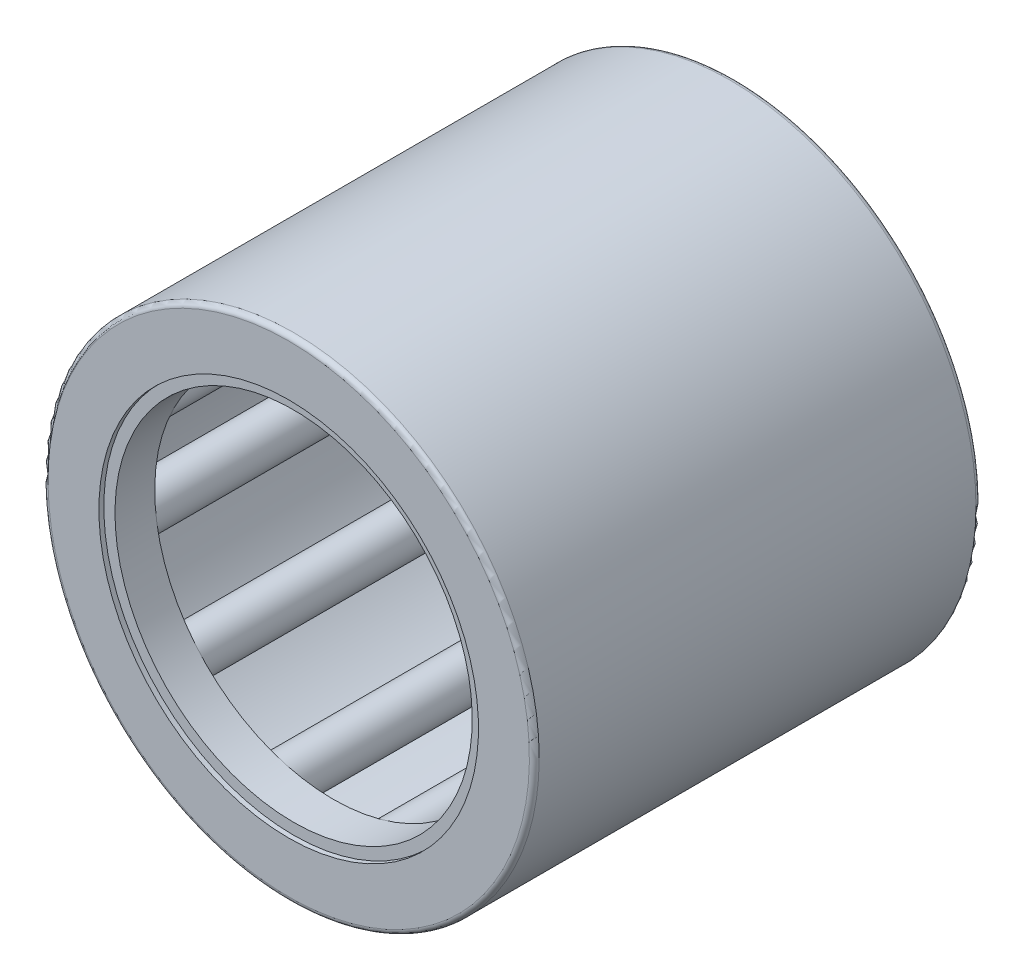
from build123d import *

# Parameters (mm, degrees)
SKETCH2_W         = 12.7
SKETCH2_H         = 0.5953125
SKETCH3_W         = 14.2875
SKETCH3_H         = 0.1984375
CIRPATTERN1_COUNT = 11
CIRPATTERN1_ANGLE = 327.272727273
FILLET1_R         = 0.174625
SKETCH4_W         = 1.412875
SKETCH4_H         = 0.396875
SKETCH5_W         = 1.412875
SKETCH5_H         = 0.396875


with BuildPart() as part:
    # Sketch1 → Revolve1 (revolve)
    with BuildSketch(Plane(origin=(0, 0, 0), x_dir=(0, 0, -1), z_dir=(1, 0, 0))):
        Polygon((-7.9375, 8.73125), (7.9375, 8.73125), (7.9375, 6.746875), (7.14375, 6.746875), (7.14375, 7.9375), (-7.14375, 7.9375), (-7.14375, 6.746875), (-7.9375, 6.746875), align=None)
    revolve(axis=Axis((0, 0, 7.9375), (0, 0, -1)))

    # Fillet1
    fillet1_edges = [part.edges().sort_by_distance(p)[0] for p in [
        (0, -8.73125, -7.9375),
        (0, -8.73125, 7.9375),
    ]]
    fillet(fillet1_edges, radius=FILLET1_R)


with BuildPart() as body_2:
    # Sketch2 → Revolve2 (revolve)
    with BuildSketch(Plane(origin=(0, 0, 0), x_dir=(0, 0, -1), z_dir=(1, 0, 0))):
        with Locations((0, 7.63984375)):
            Rectangle(SKETCH2_W, SKETCH2_H)
    revolve(axis=Axis((0, 7.14375, 6.35), (0, 0, -1)))


with BuildPart() as body_3:
    # Sketch3 → Revolve3 (revolve)
    with BuildSketch(Plane(origin=(0, 0, 0), x_dir=(0, 0, -1), z_dir=(1, 0, 0))):
        with Locations((0, 7.24296875)):
            Rectangle(SKETCH3_W, SKETCH3_H)
    revolve(axis=Axis((0, 7.14375, 7.14375), (0, 0, -1)))


with BuildPart() as cirpattern1_1:
    # CirPattern1: pattern copy
    add(body_2.part.rotate(Axis((0, 0, -7.9375), (0, 0, 1)), 1 * CIRPATTERN1_ANGLE / (CIRPATTERN1_COUNT - 1)))


with BuildPart() as cirpattern1_2:
    # CirPattern1: pattern copy
    add(body_2.part.rotate(Axis((0, 0, -7.9375), (0, 0, 1)), 2 * CIRPATTERN1_ANGLE / (CIRPATTERN1_COUNT - 1)))


with BuildPart() as cirpattern1_3:
    # CirPattern1: pattern copy
    add(body_2.part.rotate(Axis((0, 0, -7.9375), (0, 0, 1)), 3 * CIRPATTERN1_ANGLE / (CIRPATTERN1_COUNT - 1)))


with BuildPart() as cirpattern1_4:
    # CirPattern1: pattern copy
    add(body_2.part.rotate(Axis((0, 0, -7.9375), (0, 0, 1)), 4 * CIRPATTERN1_ANGLE / (CIRPATTERN1_COUNT - 1)))


with BuildPart() as cirpattern1_5:
    # CirPattern1: pattern copy
    add(body_2.part.rotate(Axis((0, 0, -7.9375), (0, 0, 1)), 5 * CIRPATTERN1_ANGLE / (CIRPATTERN1_COUNT - 1)))


with BuildPart() as cirpattern1_6:
    # CirPattern1: pattern copy
    add(body_2.part.rotate(Axis((0, 0, -7.9375), (0, 0, 1)), 6 * CIRPATTERN1_ANGLE / (CIRPATTERN1_COUNT - 1)))


with BuildPart() as cirpattern1_7:
    # CirPattern1: pattern copy
    add(body_2.part.rotate(Axis((0, 0, -7.9375), (0, 0, 1)), 7 * CIRPATTERN1_ANGLE / (CIRPATTERN1_COUNT - 1)))


with BuildPart() as cirpattern1_8:
    # CirPattern1: pattern copy
    add(body_2.part.rotate(Axis((0, 0, -7.9375), (0, 0, 1)), 8 * CIRPATTERN1_ANGLE / (CIRPATTERN1_COUNT - 1)))


with BuildPart() as cirpattern1_9:
    # CirPattern1: pattern copy
    add(body_2.part.rotate(Axis((0, 0, -7.9375), (0, 0, 1)), 9 * CIRPATTERN1_ANGLE / (CIRPATTERN1_COUNT - 1)))


with BuildPart() as cirpattern1_10:
    # CirPattern1: pattern copy
    add(body_2.part.rotate(Axis((0, 0, -7.9375), (0, 0, 1)), 10 * CIRPATTERN1_ANGLE / (CIRPATTERN1_COUNT - 1)))


with BuildPart() as cirpattern1_11:
    # CirPattern1: pattern copy
    add(body_3.part.rotate(Axis((0, 0, -7.9375), (0, 0, 1)), 1 * CIRPATTERN1_ANGLE / (CIRPATTERN1_COUNT - 1)))


with BuildPart() as cirpattern1_12:
    # CirPattern1: pattern copy
    add(body_3.part.rotate(Axis((0, 0, -7.9375), (0, 0, 1)), 2 * CIRPATTERN1_ANGLE / (CIRPATTERN1_COUNT - 1)))


with BuildPart() as cirpattern1_13:
    # CirPattern1: pattern copy
    add(body_3.part.rotate(Axis((0, 0, -7.9375), (0, 0, 1)), 3 * CIRPATTERN1_ANGLE / (CIRPATTERN1_COUNT - 1)))


with BuildPart() as cirpattern1_14:
    # CirPattern1: pattern copy
    add(body_3.part.rotate(Axis((0, 0, -7.9375), (0, 0, 1)), 4 * CIRPATTERN1_ANGLE / (CIRPATTERN1_COUNT - 1)))


with BuildPart() as cirpattern1_15:
    # CirPattern1: pattern copy
    add(body_3.part.rotate(Axis((0, 0, -7.9375), (0, 0, 1)), 5 * CIRPATTERN1_ANGLE / (CIRPATTERN1_COUNT - 1)))


with BuildPart() as cirpattern1_16:
    # CirPattern1: pattern copy
    add(body_3.part.rotate(Axis((0, 0, -7.9375), (0, 0, 1)), 6 * CIRPATTERN1_ANGLE / (CIRPATTERN1_COUNT - 1)))


with BuildPart() as cirpattern1_17:
    # CirPattern1: pattern copy
    add(body_3.part.rotate(Axis((0, 0, -7.9375), (0, 0, 1)), 7 * CIRPATTERN1_ANGLE / (CIRPATTERN1_COUNT - 1)))


with BuildPart() as cirpattern1_18:
    # CirPattern1: pattern copy
    add(body_3.part.rotate(Axis((0, 0, -7.9375), (0, 0, 1)), 8 * CIRPATTERN1_ANGLE / (CIRPATTERN1_COUNT - 1)))


with BuildPart() as cirpattern1_19:
    # CirPattern1: pattern copy
    add(body_3.part.rotate(Axis((0, 0, -7.9375), (0, 0, 1)), 9 * CIRPATTERN1_ANGLE / (CIRPATTERN1_COUNT - 1)))


with BuildPart() as cirpattern1_20:
    # CirPattern1: pattern copy
    add(body_3.part.rotate(Axis((0, 0, -7.9375), (0, 0, 1)), 10 * CIRPATTERN1_ANGLE / (CIRPATTERN1_COUNT - 1)))


with BuildPart() as body_24:
    # Sketch4 → Revolve4 (revolve)
    with BuildSketch(Plane(origin=(0, 0, 0), x_dir=(0, 0, -1), z_dir=(1, 0, 0))):
        with Locations((7.0564375, 6.5484375)):
            Rectangle(SKETCH4_W, SKETCH4_H)
    revolve(axis=Axis((0, 0, 7.9375), (0, 0, -1)))


with BuildPart() as body_25:
    # Sketch5 → Revolve5 (revolve)
    with BuildSketch(Plane(origin=(0, 0, 0), x_dir=(0, 0, -1), z_dir=(1, 0, 0))):
        with Locations((-7.0564375, 6.5484375)):
            Rectangle(SKETCH5_W, SKETCH5_H)
    revolve(axis=Axis((0, 0, 7.9375), (0, 0, -1)))


solid = Compound([part.part, body_2.part, body_3.part, cirpattern1_1.part, cirpattern1_2.part, cirpattern1_3.part, cirpattern1_4.part, cirpattern1_5.part, cirpattern1_6.part, cirpattern1_7.part, cirpattern1_8.part, cirpattern1_9.part, cirpattern1_10.part, cirpattern1_11.part, cirpattern1_12.part, cirpattern1_13.part, cirpattern1_14.part, cirpattern1_15.part, cirpattern1_16.part, cirpattern1_17.part, cirpattern1_18.part, cirpattern1_19.part, cirpattern1_20.part, body_24.part, body_25.part])
